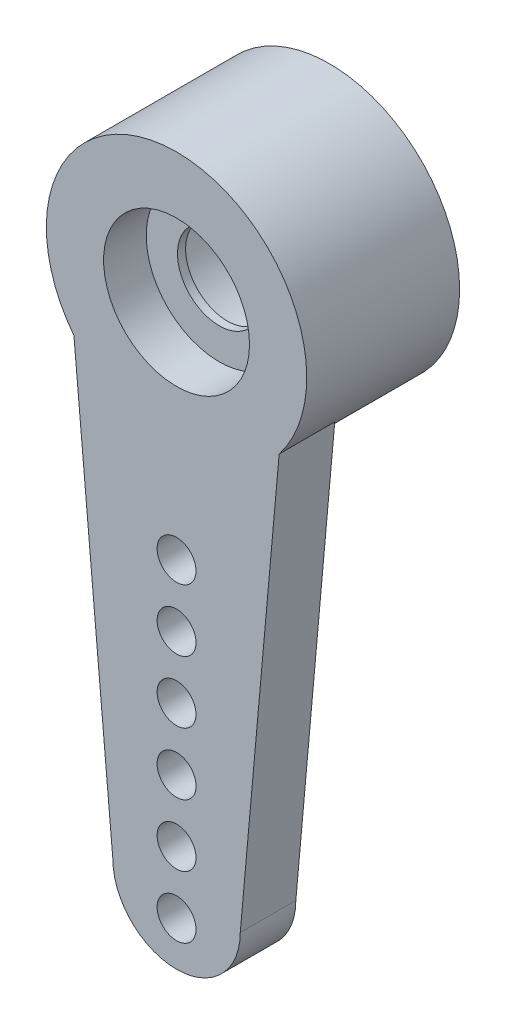
from build123d import *

# Parameters (mm, degrees)
SKETCH1_R           = 3.5687
SKETCH1_R_2         = 2
BOSS_EXTRUDE1_DEPTH = 4.191
SKETCH5_R           = 2
SKETCH5_R_2         = 1.143
BOSS_EXTRUDE2_DEPTH = 0.2226
SKETCH6_R           = 0.5334
BOSS_EXTRUDE3_DEPTH = 1.524


with BuildPart() as part:
    # Sketch1 → Boss-Extrude1 (new body)
    with BuildSketch(Plane.XY.offset(-7.032965862)):
        with Locations((-5.5, 0)):
            Circle(SKETCH1_R)
        with Locations((-5.5, 0)):
            Circle(SKETCH1_R_2, mode=Mode.SUBTRACT)
    extrude(amount=BOSS_EXTRUDE1_DEPTH)

    # Sketch5 → Boss-Extrude2 (add)
    with BuildSketch(Plane.XY.offset(-4.232965862)):
        with Locations((-5.5, 0)):
            Circle(SKETCH5_R)
        with Locations((-5.5, 0)):
            Circle(SKETCH5_R_2, mode=Mode.SUBTRACT)
    extrude(amount=BOSS_EXTRUDE2_DEPTH)

    # Sketch6 → Boss-Extrude3 (add)
    with BuildSketch(Plane.XY.offset(-2.841965862)):
        with BuildLine():
            Line((-3.75375, -14.09065), (-2.68695, -2.195989387))
            ThreePointArc((-2.68695, -2.195989387), (-5.5, -3.5687), (-8.31305, -2.195989387))
            Line((-8.31305, -2.195989387), (-7.24625, -14.09065))
            ThreePointArc((-7.24625, -14.09065), (-5.5, -15.8369), (-3.75375, -14.09065))
        make_face()
        with Locations((-5.5, -12.92225)):
            Circle(SKETCH6_R, mode=Mode.SUBTRACT)
        with Locations((-5.5, -14.62405)):
            Circle(SKETCH6_R, mode=Mode.SUBTRACT)
        with Locations((-5.5, -11.22045)):
            Circle(SKETCH6_R, mode=Mode.SUBTRACT)
        with Locations((-5.5, -9.51865)):
            Circle(SKETCH6_R, mode=Mode.SUBTRACT)
        with Locations((-5.5, -7.81685)):
            Circle(SKETCH6_R, mode=Mode.SUBTRACT)
        with Locations((-5.5, -6.11505)):
            Circle(SKETCH6_R, mode=Mode.SUBTRACT)
    extrude(amount=-BOSS_EXTRUDE3_DEPTH)


solid = part.part
